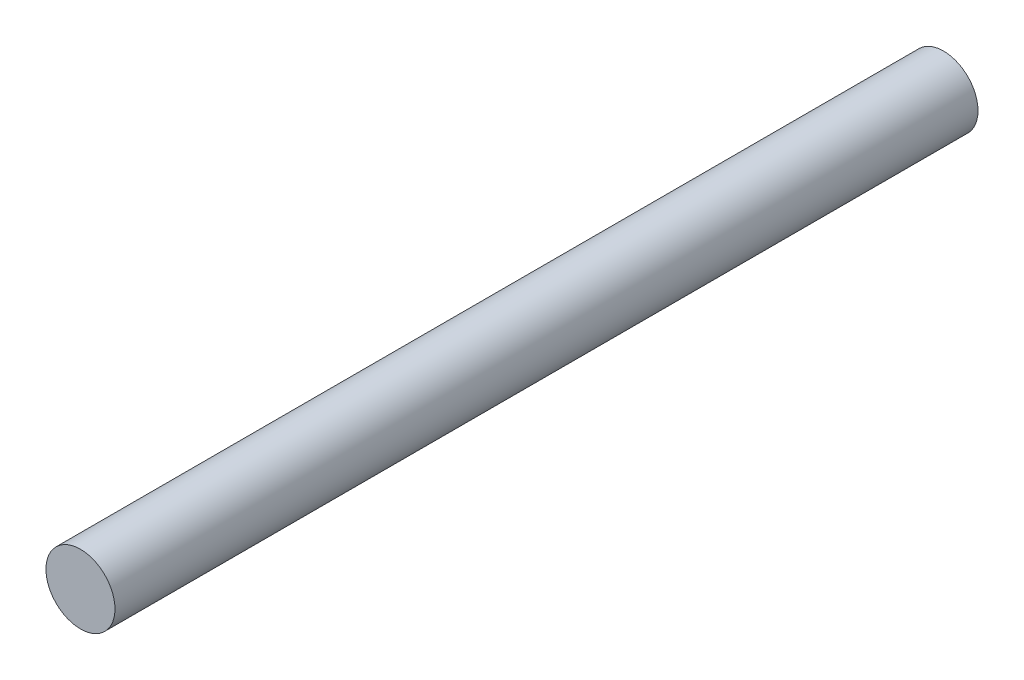
from build123d import *

# Parameters (mm, degrees)
SKETCH1_R           = 1
BOSS_EXTRUDE1_DEPTH = 25


with BuildPart() as part:
    # Sketch1 → Boss-Extrude1 (new body)
    with BuildSketch(Plane.XY):
        Circle(SKETCH1_R)
    extrude(amount=BOSS_EXTRUDE1_DEPTH)


solid = part.part
